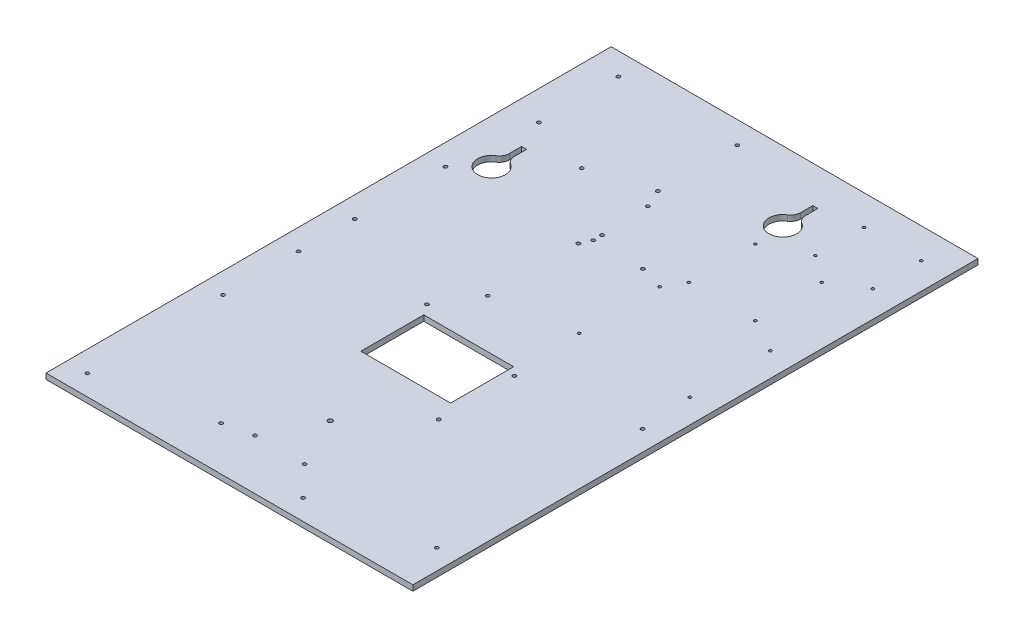
from build123d import *

# Parameters (mm, degrees)
SKETCH1_R           = 1.778
SKETCH1_R_2         = 1.397
BOSS_EXTRUDE1_DEPTH = 5.6388
SKETCH5_R           = 2.39395
CUT_EXTRUDE1_DEPTH  = 6.6388
SKETCH6_R           = 1.778
CUT_EXTRUDE2_DEPTH  = 6.6388
SKETCH7_W           = 90.6
SKETCH7_H           = 63.5
CUT_EXTRUDE3_DEPTH  = 6.6388


with BuildPart() as part:
    # Sketch1 → Boss-Extrude1 (new body)
    with BuildSketch(Plane(origin=(0, 0, 0), x_dir=(1, 0, 0), z_dir=(0, 1, 0))):
        Polygon((-836.762809235, 790.243336478), (-836.762809235, 232.943336478), (-836.762809235, 226.593336478), (-466.762809235, 226.593336478), (-466.762809235, 232.943336478), (-466.762809235, 790.243336478), (-466.762809235, 796.593336478), (-836.762809235, 796.593336478), align=None)
        with Locations((-807.062809235, 774.087336478)):
            Circle(SKETCH1_R, mode=Mode.SUBTRACT)
        with Locations((-807.062809235, 694.087336478)):
            Circle(SKETCH1_R, mode=Mode.SUBTRACT)
        with Locations((-687.062809235, 694.087336478)):
            Circle(SKETCH1_R, mode=Mode.SUBTRACT)
        with Locations((-687.062809235, 774.087336478)):
            Circle(SKETCH1_R, mode=Mode.SUBTRACT)
        with Locations((-551.437809235, 766.168335733)):
            Circle(SKETCH1_R_2, mode=Mode.SUBTRACT)
        with Locations((-551.437809235, 717.168335733)):
            Circle(SKETCH1_R_2, mode=Mode.SUBTRACT)
        with Locations((-493.437809235, 717.168335733)):
            Circle(SKETCH1_R_2, mode=Mode.SUBTRACT)
        with Locations((-493.437809235, 766.168335733)):
            Circle(SKETCH1_R_2, mode=Mode.SUBTRACT)
        with Locations((-591.737808414, 696.968336156)):
            Circle(SKETCH1_R_2, mode=Mode.SUBTRACT)
        with Locations((-591.737808414, 629.968336156)):
            Circle(SKETCH1_R_2, mode=Mode.SUBTRACT)
        with Locations((-524.737808414, 629.968336156)):
            Circle(SKETCH1_R_2, mode=Mode.SUBTRACT)
        with Locations((-524.737808414, 696.968336156)):
            Circle(SKETCH1_R_2, mode=Mode.SUBTRACT)
        with Locations((-815.553809235, 608.213336478)):
            Circle(SKETCH1_R, mode=Mode.SUBTRACT)
        with Locations((-681.441809235, 608.213336478)):
            Circle(SKETCH1_R, mode=Mode.SUBTRACT)
        with Locations((-681.441809235, 516.773336478)):
            Circle(SKETCH1_R, mode=Mode.SUBTRACT)
        with Locations((-815.553809235, 516.773336478)):
            Circle(SKETCH1_R, mode=Mode.SUBTRACT)
        with Locations((-602.652809235, 611.403336478)):
            Circle(SKETCH1_R_2, mode=Mode.SUBTRACT)
        with Locations((-602.652809235, 530.123336478)):
            Circle(SKETCH1_R_2, mode=Mode.SUBTRACT)
        with Locations((-490.892809235, 611.403336478)):
            Circle(SKETCH1_R_2, mode=Mode.SUBTRACT)
        with Locations((-490.892809235, 530.123336478)):
            Circle(SKETCH1_R_2, mode=Mode.SUBTRACT)
        with Locations((-487.082809235, 478.673336478)):
            Circle(SKETCH1_R, mode=Mode.SUBTRACT)
        with Locations((-598.080809235, 460.258336478)):
            Circle(SKETCH1_R, mode=Mode.SUBTRACT)
        with Locations((-598.080809235, 384.058336478)):
            Circle(SKETCH1_R, mode=Mode.SUBTRACT)
        with Locations((-487.082809235, 271.091836478)):
            Circle(SKETCH1_R, mode=Mode.SUBTRACT)
        with Locations((-598.080809235, 247.152336478)):
            Circle(SKETCH1_R, mode=Mode.SUBTRACT)
        with Locations((-704.682809235, 271.091836478)):
            Circle(SKETCH1_R, mode=Mode.SUBTRACT)
        with Locations((-815.680809235, 247.152336478)):
            Circle(SKETCH1_R, mode=Mode.SUBTRACT)
        with Locations((-815.680809235, 384.058336478)):
            Circle(SKETCH1_R, mode=Mode.SUBTRACT)
        with Locations((-815.680809235, 460.258336478)):
            Circle(SKETCH1_R, mode=Mode.SUBTRACT)
        with Locations((-704.682809235, 478.673336478)):
            Circle(SKETCH1_R, mode=Mode.SUBTRACT)
        with Locations((-678.940809235, 675.739236478)):
            Circle(SKETCH1_R, mode=Mode.SUBTRACT)
        with Locations((-745.539609235, 675.739236478)):
            Circle(SKETCH1_R, mode=Mode.SUBTRACT)
        with Locations((-676.790809235, 627.495236478)):
            Circle(SKETCH1_R, mode=Mode.SUBTRACT)
    extrude(amount=BOSS_EXTRUDE1_DEPTH)

    # Sketch5 → Cut-Extrude1 (cut, through all)
    with BuildSketch(Plane.XZ):
        with Locations((-651.762809235, -328.193336478)):
            Circle(SKETCH5_R)
        with BuildLine():
            Line((-794.852809235, -664.280486837), (-794.852809235, -651.921486174))
            ThreePointArc((-794.852809235, -651.921486174), (-796.125971484, -647.038628109), (-799.62126981, -643.399104156))
            ThreePointArc((-799.62126981, -643.399104156), (-792.312809235, -617.523336478), (-785.004348659, -643.399104156))
            ThreePointArc((-785.004348659, -643.399104156), (-788.499646985, -647.038628109), (-789.772809235, -651.921486174))
            Line((-789.772809235, -651.921486174), (-789.772809235, -664.280486837))
            Line((-789.772809235, -664.280486837), (-794.852809235, -664.280486837))
        make_face()
        with BuildLine():
            Line((-596.302809235, -759.530486837), (-596.302809235, -747.171486174))
            ThreePointArc((-596.302809235, -747.171486174), (-597.575971484, -742.288628109), (-601.07126981, -738.649104156))
            ThreePointArc((-601.07126981, -738.649104156), (-593.762809235, -712.773336478), (-586.454348659, -738.649104156))
            ThreePointArc((-586.454348659, -738.649104156), (-589.949646985, -742.288628109), (-591.222809235, -747.171486174))
            Line((-591.222809235, -747.171486174), (-591.222809235, -759.530486837))
            Line((-591.222809235, -759.530486837), (-596.302809235, -759.530486837))
        make_face()
    extrude(amount=-CUT_EXTRUDE1_DEPTH, mode=Mode.SUBTRACT)

    # Sketch6 → Cut-Extrude2 (cut, through all)
    with BuildSketch(Plane(origin=(0, 5.6388, 0), x_dir=(1, 0, 0), z_dir=(0, 1, 0))):
        with Locations((-676.762809235, 277.393336478)):
            Circle(SKETCH6_R)
        with Locations((-626.762809235, 277.393336478)):
            Circle(SKETCH6_R)
        with Locations((-676.762809235, 618.593336478)):
            Circle(SKETCH6_R)
        with Locations((-626.762809235, 618.593336478)):
            Circle(SKETCH6_R)
    extrude(amount=-CUT_EXTRUDE2_DEPTH, mode=Mode.SUBTRACT)

    # Sketch7 → Cut-Extrude3 (cut, through all)
    with BuildSketch(Plane(origin=(0, 5.6388, 0), x_dir=(1, 0, 0), z_dir=(0, 1, 0))):
        with Locations((-651.762809235, 436.143336478)):
            Rectangle(SKETCH7_W, SKETCH7_H)
    extrude(amount=-CUT_EXTRUDE3_DEPTH, mode=Mode.SUBTRACT)


solid = part.part
